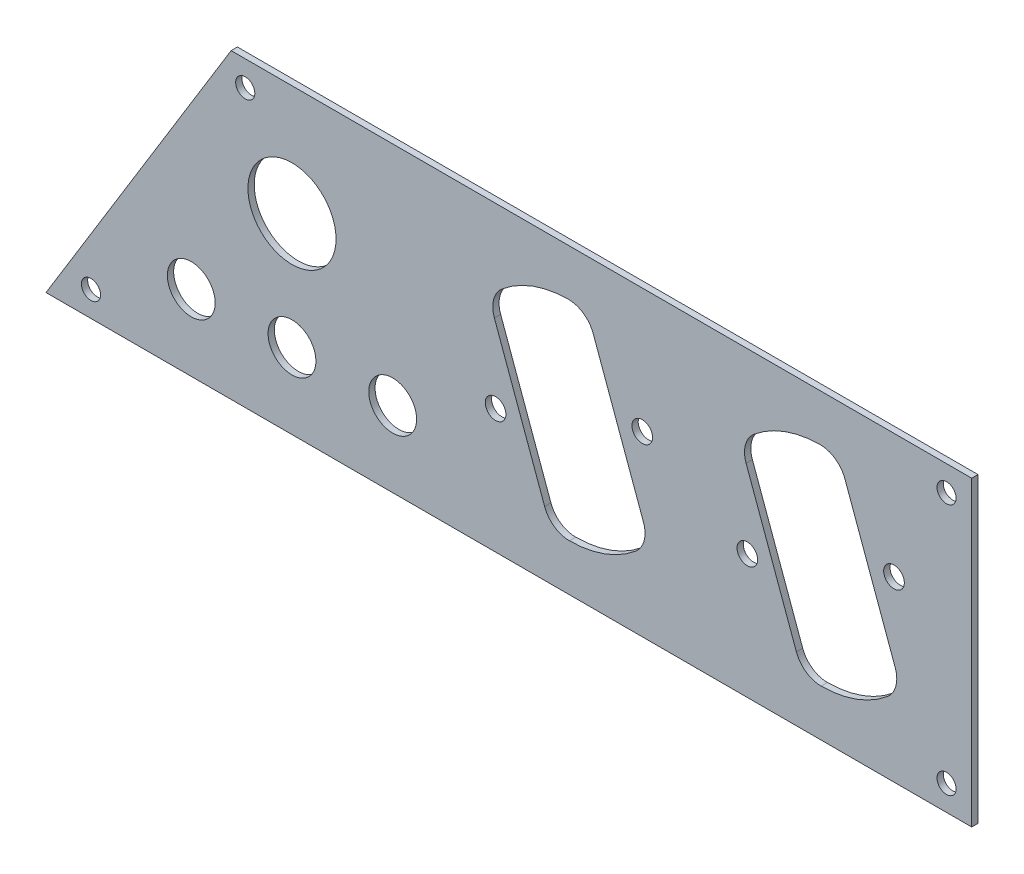
from build123d import *

# Parameters (mm, degrees)
SKETCH1_R   = 11.1125
SKETCH1_R_2 = 6.0325
SKETCH1_R_3 = 2.413
SKETCH1_R_4 = 2.6035
PANEL_DEPTH = 1.5875


with BuildPart() as part:
    # Sketch1 → Panel (new body)
    with BuildSketch(Plane.XY):
        Polygon((-233.495394339, -381), (-186.796315472, -304.8), (0, -304.8), (0, -381), align=None)
        with Locations((-171.45, -332.74)):
            Circle(SKETCH1_R, mode=Mode.SUBTRACT)
        with Locations((-196.85, -361.95)):
            Circle(SKETCH1_R_2, mode=Mode.SUBTRACT)
        with Locations((-171.45, -361.95)):
            Circle(SKETCH1_R_2, mode=Mode.SUBTRACT)
        with Locations((-146.05, -361.95)):
            Circle(SKETCH1_R_2, mode=Mode.SUBTRACT)
        with Locations((-6.35, -311.15)):
            Circle(SKETCH1_R_3, mode=Mode.SUBTRACT)
        with Locations((-6.35, -374.65)):
            Circle(SKETCH1_R_3, mode=Mode.SUBTRACT)
        with Locations((-222.156189245, -374.65)):
            Circle(SKETCH1_R_3, mode=Mode.SUBTRACT)
        with Locations((-183.240290189, -311.15)):
            Circle(SKETCH1_R_3, mode=Mode.SUBTRACT)
        with Locations((-19.60215076, -336.167333479)):
            Circle(SKETCH1_R_4, mode=Mode.SUBTRACT)
        with Locations((-56.59784924, -349.632666521)):
            Circle(SKETCH1_R_4, mode=Mode.SUBTRACT)
        with Locations((-83.10215076, -336.167333479)):
            Circle(SKETCH1_R_4, mode=Mode.SUBTRACT)
        with Locations((-120.09784924, -349.632666521)):
            Circle(SKETCH1_R_4, mode=Mode.SUBTRACT)
        with BuildLine():
            Line((-56.904231841, -330.003007558), (-44.214850365, -364.866796631))
            ThreePointArc((-44.214850365, -364.866796631), (-41.786616314, -368.025044915), (-37.983738549, -369.212046828))
            ThreePointArc((-37.983738549, -369.212046828), (-29.099761225, -367.627952805), (-21.276003752, -363.13092868))
            ThreePointArc((-21.276003752, -363.13092868), (-19.125820494, -359.777189752), (-19.295768159, -355.796992442))
            Line((-19.295768159, -355.796992442), (-31.985149635, -320.933203369))
            ThreePointArc((-31.985149635, -320.933203369), (-34.413383686, -317.774955085), (-38.216261451, -316.587953172))
            ThreePointArc((-38.216261451, -316.587953172), (-47.100238775, -318.172047195), (-54.923996248, -322.66907132))
            ThreePointArc((-54.923996248, -322.66907132), (-57.074179506, -326.022810248), (-56.904231841, -330.003007558))
        make_face(mode=Mode.SUBTRACT)
        with BuildLine():
            Line((-120.404231841, -330.003007558), (-107.714850365, -364.866796631))
            ThreePointArc((-107.714850365, -364.866796631), (-105.286616314, -368.025044915), (-101.483738549, -369.212046828))
            ThreePointArc((-101.483738549, -369.212046828), (-92.599761225, -367.627952805), (-84.776003752, -363.13092868))
            ThreePointArc((-84.776003752, -363.13092868), (-82.625820494, -359.777189752), (-82.795768159, -355.796992442))
            Line((-82.795768159, -355.796992442), (-95.485149635, -320.933203369))
            ThreePointArc((-95.485149635, -320.933203369), (-97.913383686, -317.774955085), (-101.716261451, -316.587953172))
            ThreePointArc((-101.716261451, -316.587953172), (-110.600238775, -318.172047195), (-118.423996248, -322.66907132))
            ThreePointArc((-118.423996248, -322.66907132), (-120.574179506, -326.022810248), (-120.404231841, -330.003007558))
        make_face(mode=Mode.SUBTRACT)
    extrude(amount=PANEL_DEPTH)


solid = part.part
